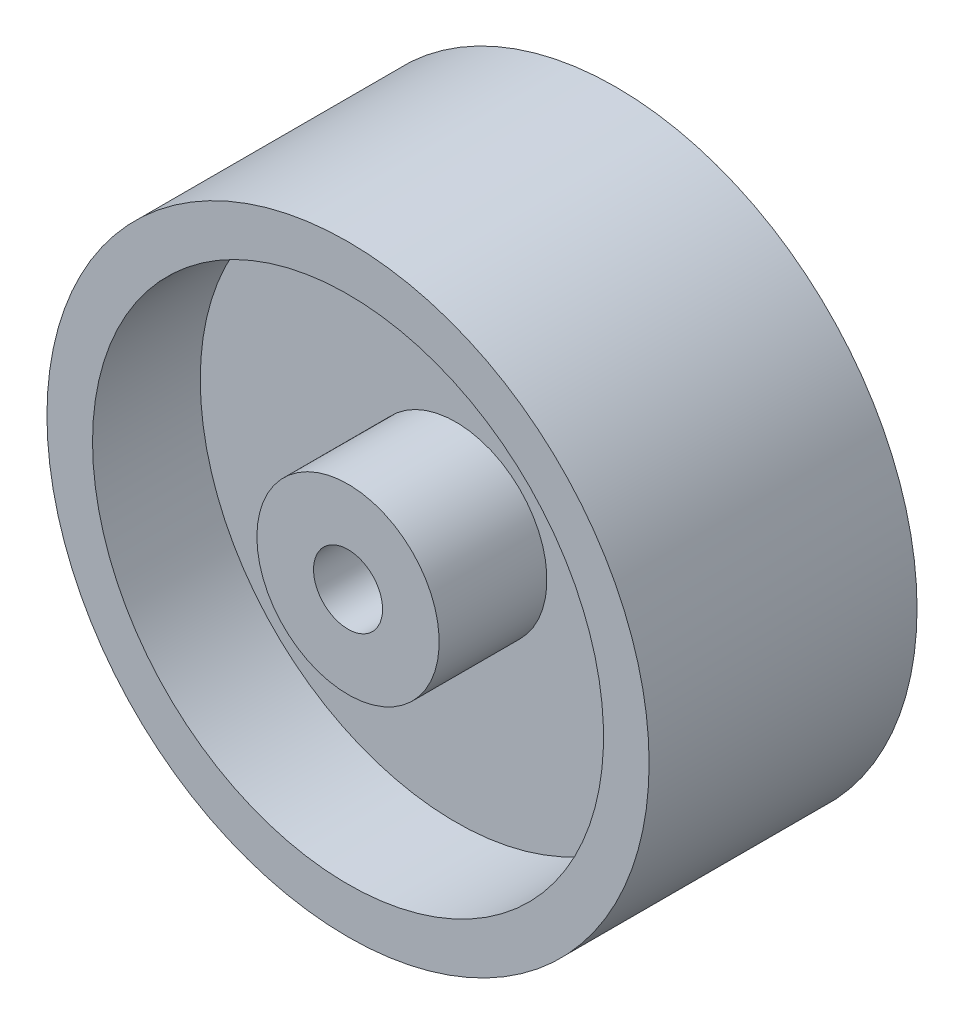
from build123d import *

# Parameters (mm, degrees)
SKETCH1_R           = 27.686
BOSS_EXTRUDE1_DEPTH = 12.319
SKETCH2_W           = 9.906
SKETCH2_H           = 15.113
SKETCH3_R           = 3.175
CUT_EXTRUDE1_DEPTH  = 25.638


with BuildPart() as part:
    # Sketch1 → Boss-Extrude1 (new body, symmetric)
    with BuildSketch(Plane.XY):
        Circle(SKETCH1_R)
    extrude(amount=BOSS_EXTRUDE1_DEPTH, both=True)

    # Sketch2 → Cut-Revolve1 (revolve, cut)
    with BuildSketch(Plane(origin=(0, 0, 0), x_dir=(0, 0, -1), z_dir=(1, 0, 0))):
        with Locations((-7.366, 15.9385)):
            Rectangle(SKETCH2_W, SKETCH2_H)
    cut_revolve1 = revolve(axis=Axis((0, 0, 0), (0, 0, 1)), mode=Mode.SUBTRACT)

    # Sketch3 → Cut-Extrude1 (cut, through all)
    with BuildSketch(Plane.XY.offset(12.319)):
        Circle(SKETCH3_R)
    extrude(amount=-CUT_EXTRUDE1_DEPTH, mode=Mode.SUBTRACT)

    # Mirror1: Cut-Revolve1 across plane
    add(cut_revolve1.mirror(Plane.XY), mode=Mode.SUBTRACT)


solid = part.part
